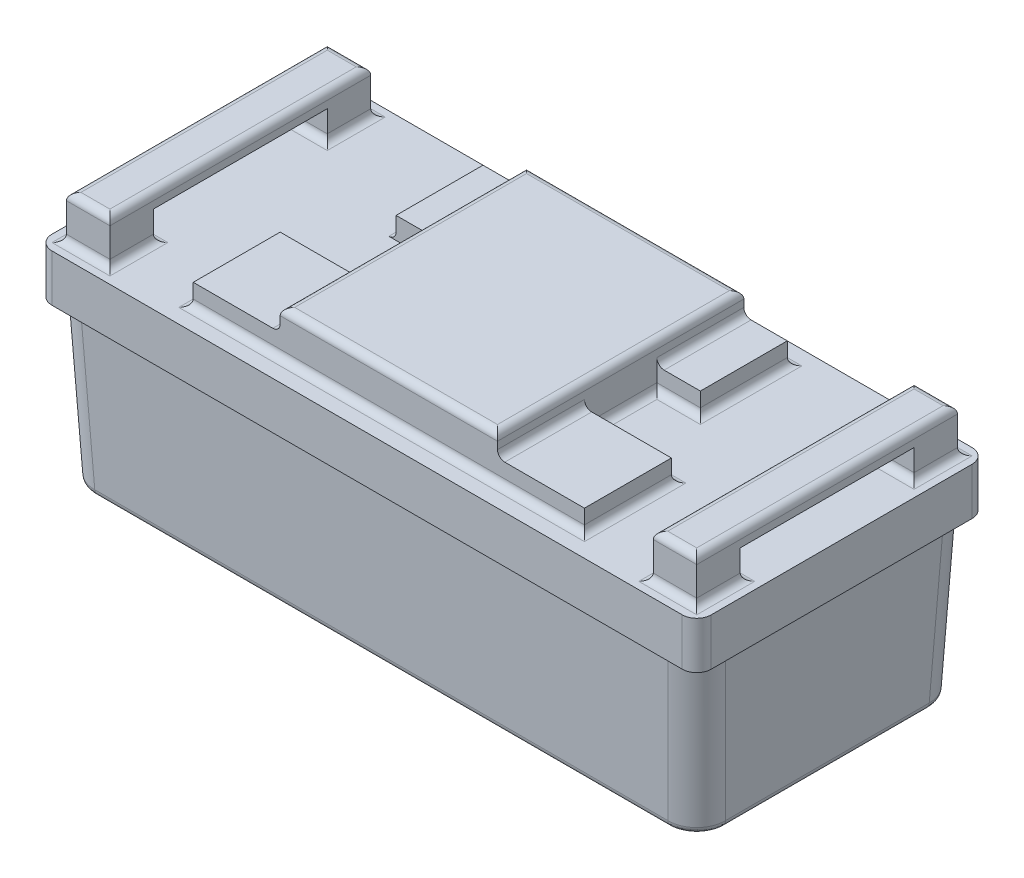
from build123d import *

# Parameters (mm, degrees)
SKETCH1_W           = 577.85
SKETCH1_H           = 254
BOSS_EXTRUDE1_DEPTH = 41.275
SKETCH2_W           = 38.1
SKETCH2_H           = 228.6
BOSS_EXTRUDE2_DEPTH = 38.1
SKETCH3_W           = 152.4
SKETCH3_H           = 25.4
CUT_EXTRUDE1_DEPTH  = 552.45
SKETCH4_W           = 342.9
SKETCH4_H           = 215.9
BOSS_EXTRUDE3_DEPTH = 38.1
CUT_EXTRUDE2_DEPTH  = 38.1
SKETCH7_W           = 76.2
SKETCH7_H           = 76.2
SKETCH7_W_2         = 38.1
CUT_EXTRUDE3_DEPTH  = 19.05
FILLET1_R           = 6.35
FILLET2_R           = 12.7
SKETCH8_W           = 565.15
SKETCH8_H           = 241.3
SKETCH9_W           = 552.45
SKETCH9_H           = 228.6
FILLET3_R           = 25.4
FILLET4_R           = 6.35


with BuildPart() as part:
    # Sketch1 → Boss-Extrude1 (new body)
    with BuildSketch(Plane(origin=(0, 0, 0), x_dir=(1, 0, 0), z_dir=(0, 1, 0))):
        Rectangle(SKETCH1_W, SKETCH1_H)
    extrude(amount=BOSS_EXTRUDE1_DEPTH)

    # Sketch2 → Boss-Extrude2 (add)
    with BuildSketch(Plane(origin=(0, 41.275, 0), x_dir=(1, 0, 0), z_dir=(0, 1, 0))):
        with Locations((-257.175, 0)):
            Rectangle(SKETCH2_W, SKETCH2_H)
        with Locations((257.175, 0)):
            Rectangle(SKETCH2_W, SKETCH2_H)
    extrude(amount=BOSS_EXTRUDE2_DEPTH)

    # Sketch3 → Cut-Extrude1 (cut)
    with BuildSketch(Plane.ZY.offset(276.225)):
        with Locations((0, 53.975)):
            Rectangle(SKETCH3_W, SKETCH3_H)
    extrude(amount=-CUT_EXTRUDE1_DEPTH, mode=Mode.SUBTRACT)

    # Sketch4 → Boss-Extrude3 (add)
    with BuildSketch(Plane(origin=(0, 41.275, 0), x_dir=(1, 0, 0), z_dir=(0, 1, 0))):
        Rectangle(SKETCH4_W, SKETCH4_H)
    extrude(amount=BOSS_EXTRUDE3_DEPTH)

    # Sketch6 → Cut-Extrude2 (cut)
    with BuildSketch(Plane(origin=(0, 79.375, 0), x_dir=(1, 0, 0), z_dir=(0, 1, 0))):
        Polygon((-171.45, -31.75), (-95.25, -31.75), (-95.25, 31.75), (-133.35, 31.75), (-133.35, 107.95), (-171.45, 107.95), align=None)
        Polygon((95.25, -31.75), (171.45, -31.75), (171.45, 107.95), (133.35, 107.95), (133.35, 31.75), (95.25, 31.75), align=None)
    extrude(amount=-CUT_EXTRUDE2_DEPTH, mode=Mode.SUBTRACT)

    # Sketch7 → Cut-Extrude3 (cut)
    with BuildSketch(Plane(origin=(0, 79.375, 0), x_dir=(1, 0, 0), z_dir=(0, 1, 0))):
        with Locations((-133.35, -69.85)):
            Rectangle(SKETCH7_W, SKETCH7_H)
        with Locations((-114.3, 69.85)):
            Rectangle(SKETCH7_W_2, SKETCH7_H)
        with Locations((114.3, 69.85)):
            Rectangle(SKETCH7_W_2, SKETCH7_H)
        with Locations((133.35, -69.85)):
            Rectangle(SKETCH7_W, SKETCH7_H)
    extrude(amount=-CUT_EXTRUDE3_DEPTH, mode=Mode.SUBTRACT)

    # Fillet1
    fillet1_edges = [part.edges().sort_by_distance(p)[0] for p in [
        (-257.175, 41.275, 114.3),
        (-276.225, 41.275, 95.25),
        (-257.175, 41.275, 76.2),
        (-238.125, 41.275, 95.25),
        (0, 41.275, 107.95),
        (-171.45, 41.275, 69.85),
        (-133.35, 41.275, 31.75),
        (-95.25, 41.275, 0),
        (-133.35, 41.275, -69.85),
        (0, 41.275, -107.95),
        (133.35, 41.275, -69.85),
        (114.3, 41.275, -31.75),
        (95.25, 41.275, 0),
        (133.35, 41.275, 31.75),
        (171.45, 41.275, 69.85),
        (238.125, 41.275, 95.25),
        (257.175, 41.275, 76.2),
        (276.225, 41.275, 95.25),
        (257.175, 41.275, 114.3),
        (-238.125, 41.275, -95.25),
        (-257.175, 41.275, -76.2),
        (-276.225, 41.275, -95.25),
        (-257.175, 41.275, -114.3),
        (276.225, 41.275, -95.25),
        (257.175, 41.275, -76.2),
        (238.125, 41.275, -95.25),
        (257.175, 41.275, -114.3),
        (257.175, 79.375, -114.3),
        (276.225, 79.375, 0),
        (257.175, 79.375, 114.3),
        (238.125, 79.375, 0),
        (-257.175, 79.375, -114.3),
        (-238.125, 79.375, 0),
        (-257.175, 79.375, 114.3),
        (-276.225, 79.375, 0),
        (95.25, 60.325, 69.85),
        (95.25, 79.375, 0),
        (95.25, 60.325, -69.85),
        (0, 79.375, -107.95),
        (-95.25, 79.375, 0),
        (0, 79.375, 107.95),
        (-95.25, 60.325, -69.85),
        (-95.25, 60.325, 69.85),
    ]]
    fillet(fillet1_edges, radius=FILLET1_R)

    # Fillet2
    fillet2_edges = [part.edges().sort_by_distance(p)[0] for p in [
        (288.925, 20.6375, 127),
        (-288.925, 20.6375, 127),
        (-288.925, 20.6375, -127),
        (288.925, 20.6375, -127),
    ]]
    fillet(fillet2_edges, radius=FILLET2_R)

    # Sketch8 → Loft1 section 0
    with BuildSketch(Plane.XZ):
        Rectangle(SKETCH8_W, SKETCH8_H)
    # Sketch9 → Loft1 section 1
    with BuildSketch(Plane(origin=(0, -139.7, 0), x_dir=(-1, 0, 0), z_dir=(0, -1, 0))):
        Rectangle(SKETCH9_W, SKETCH9_H)
    loft()

    # Fillet3
    fillet3_edges = [part.edges().sort_by_distance(p)[0] for p in [
        (279.4, -69.85, 117.475),
        (279.4, -69.85, -117.475),
        (-279.4, -69.85, 117.475),
        (-279.4, -69.85, -117.475),
    ]]
    fillet(fillet3_edges, radius=FILLET3_R)

    # Fillet4
    fillet4_edges = [part.edges().sort_by_distance(p)[0] for p in [
        (268.796356352, -139.7, 106.871356352),
        (276.225, -139.7, 0),
        (268.796356352, -139.7, -106.871356352),
        (0, -139.7, -114.3),
        (-268.796356352, -139.7, -106.871356352),
        (-276.225, -139.7, 0),
        (-268.796356352, -139.7, 106.871356352),
        (0, -139.7, 114.3),
    ]]
    fillet(fillet4_edges, radius=FILLET4_R)


solid = part.part
